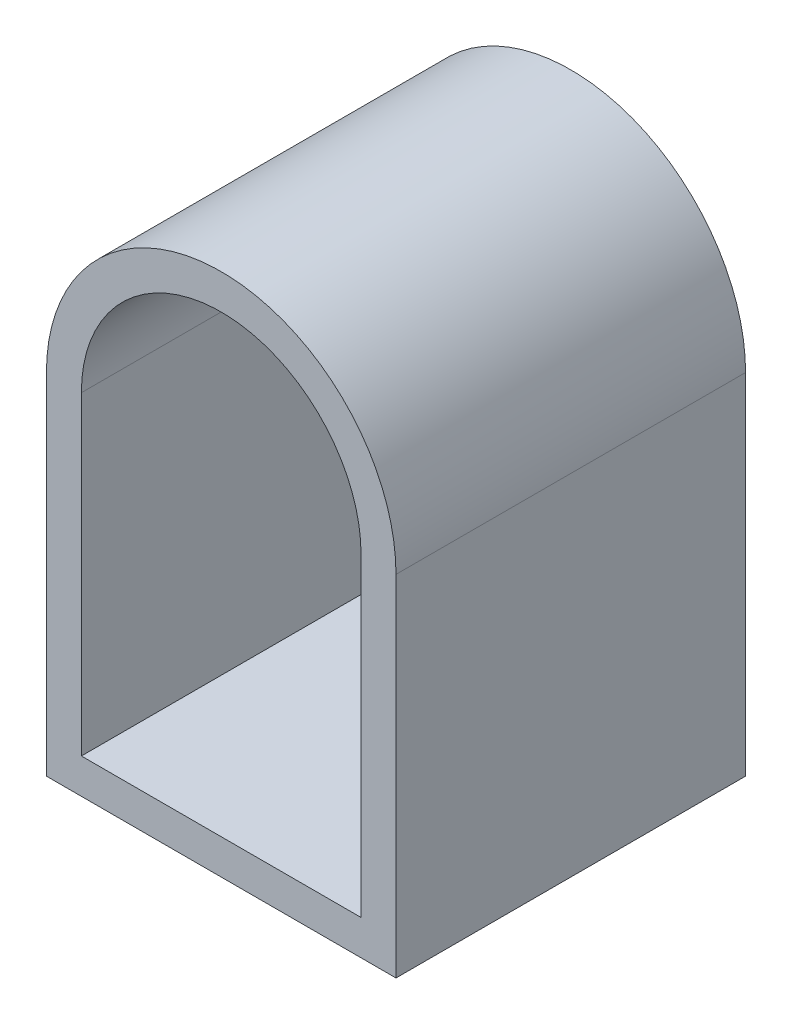
from build123d import *

# Parameters (mm, degrees)
BOSS_EXTRUDE1_DEPTH = 12.7


with BuildPart() as part:
    # Sketch1 → Boss-Extrude1 (new body)
    with BuildSketch(Plane.XY):
        with BuildLine():
            Line((0, 0), (0, 12.7))
            ThreePointArc((0, 12.7), (6.35, 19.05), (12.7, 12.7))
            Line((12.7, 12.7), (12.7, 0))
            Line((12.7, 0), (0, 0))
        make_face()
        with BuildLine():
            Line((1.27, 1.27), (11.43, 1.27))
            Line((11.43, 1.27), (11.43, 12.7))
            ThreePointArc((11.43, 12.7), (6.35, 17.78), (1.27, 12.7))
            Line((1.27, 12.7), (1.27, 1.27))
        make_face(mode=Mode.SUBTRACT)
    extrude(amount=BOSS_EXTRUDE1_DEPTH)


solid = part.part
